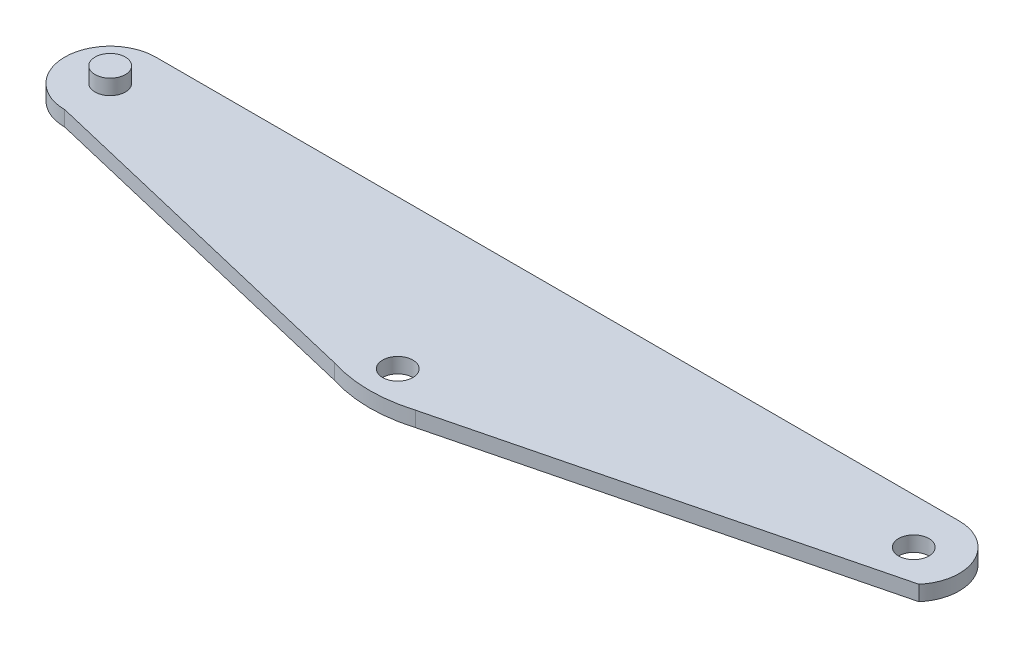
from build123d import *

# Parameters (mm, degrees)
SKETCH1_R           = 1
BOSS_EXTRUDE1_DEPTH = 1
SKETCH2_R           = 1
BOSS_EXTRUDE2_DEPTH = 1
SKETCH3_R           = 1
BOSS_EXTRUDE3_DEPTH = 1


with BuildPart() as part:
    # Sketch1 → Boss-Extrude1 (new body)
    with BuildSketch(Plane(origin=(0, 0, 0), x_dir=(1, 0, 0), z_dir=(0, 1, 0))):
        with BuildLine():
            Line((-26.5, 3), (26.5, 3))
            ThreePointArc((26.5, 3), (29.222667474, 1.259794359), (28.786667416, -1.941945449))
            Line((28.786667416, -1.941945449), (2.247877744, -8.598102408))
            ThreePointArc((2.247877744, -8.598102408), (-0.45558898, -8.991146774), (-3.153897824, -8.56412735))
            Line((-3.153897824, -8.56412735), (-26.5, -3))
            ThreePointArc((-26.5, -3), (-29.5, 0), (-26.5, 3))
        make_face()
        with Locations((-26.5, 0)):
            Circle(SKETCH1_R, mode=Mode.SUBTRACT)
        with Locations((26.5, 0)):
            Circle(SKETCH1_R, mode=Mode.SUBTRACT)
        with Locations((-0.709607331, -6.824747005)):
            Circle(SKETCH1_R, mode=Mode.SUBTRACT)
    extrude(amount=BOSS_EXTRUDE1_DEPTH)



with BuildPart() as body_2:
    # Sketch2 → Boss-Extrude2 (new body)
    with BuildSketch(Plane(origin=(0, 1, 0), x_dir=(1, 0, 0), z_dir=(0, 1, 0))):
        with Locations((-26.5, 0)):
            Circle(SKETCH2_R)
    extrude(amount=BOSS_EXTRUDE2_DEPTH)


with BuildPart() as part_1:
    add(part.part)

    add(body_2.part)  # Boss-Extrude3 merges body 2
    # Sketch3 → Boss-Extrude3 (add)
    with BuildSketch(Plane.XZ):
        with Locations((-26.5, 0)):
            Circle(SKETCH3_R)
    extrude(amount=-BOSS_EXTRUDE3_DEPTH)


solid = part_1.part
